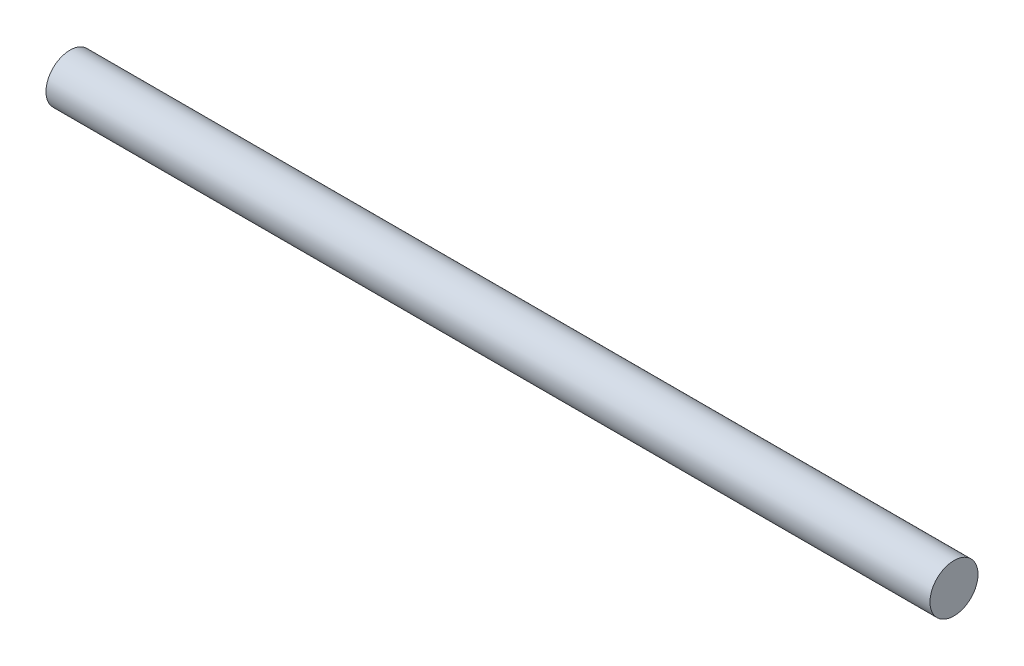
from build123d import *

# Parameters (mm, degrees)
SKETCH1_R           = 6.35
BOSS_EXTRUDE1_DEPTH = 233.68


with BuildPart() as part:
    # Sketch1 → Boss-Extrude1 (new body)
    with BuildSketch(Plane(origin=(0, 0, 0), x_dir=(0, 0, -1), z_dir=(1, 0, 0))):
        Circle(SKETCH1_R)
    extrude(amount=BOSS_EXTRUDE1_DEPTH)


solid = part.part
